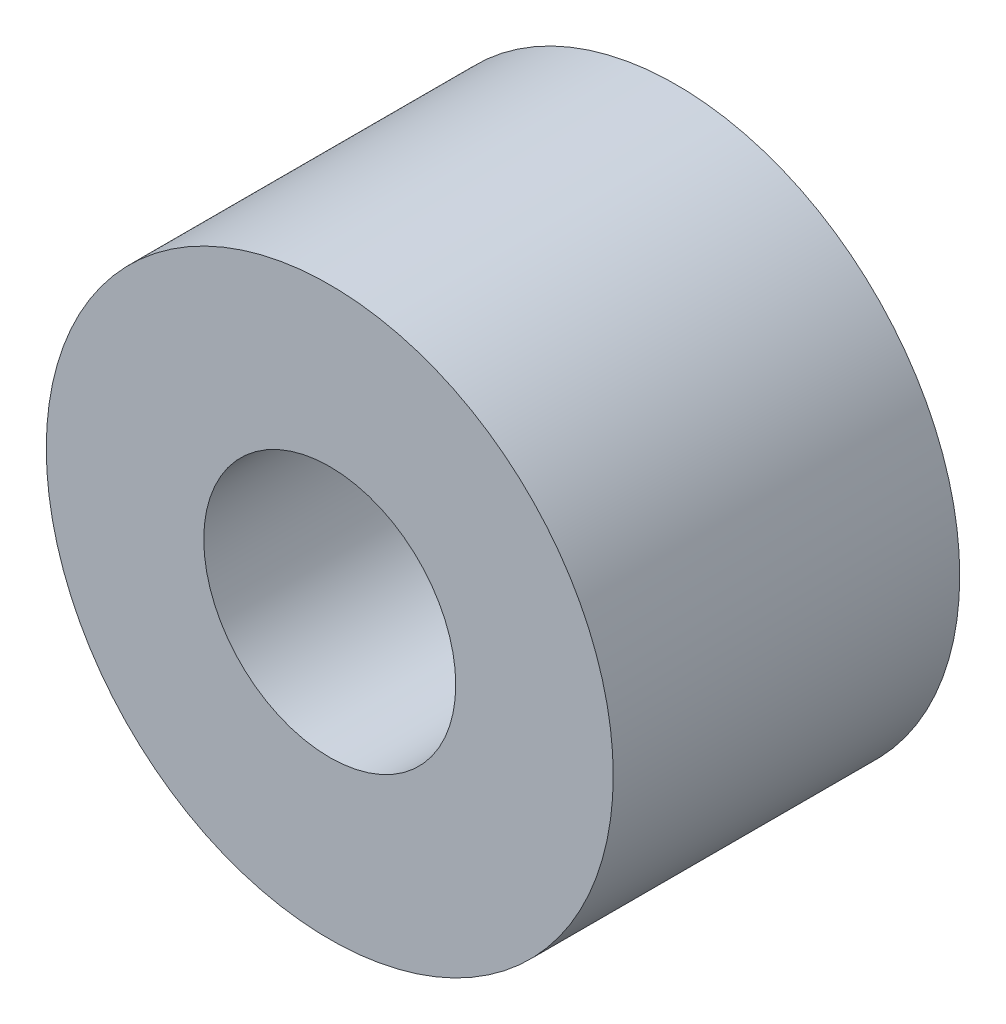
from build123d import *

# Parameters (mm, degrees)
SKETCH_1_R      = 4.5
SKETCH_1_R_2    = 2
EXTRUDE_1_DEPTH = 5.5


with BuildPart() as part:
    # 草图1 → 凸台-拉伸1 (new body)
    with BuildSketch(Plane.XY):
        Circle(SKETCH_1_R)
        Circle(SKETCH_1_R_2, mode=Mode.SUBTRACT)
    extrude(amount=EXTRUDE_1_DEPTH)


solid = part.part
